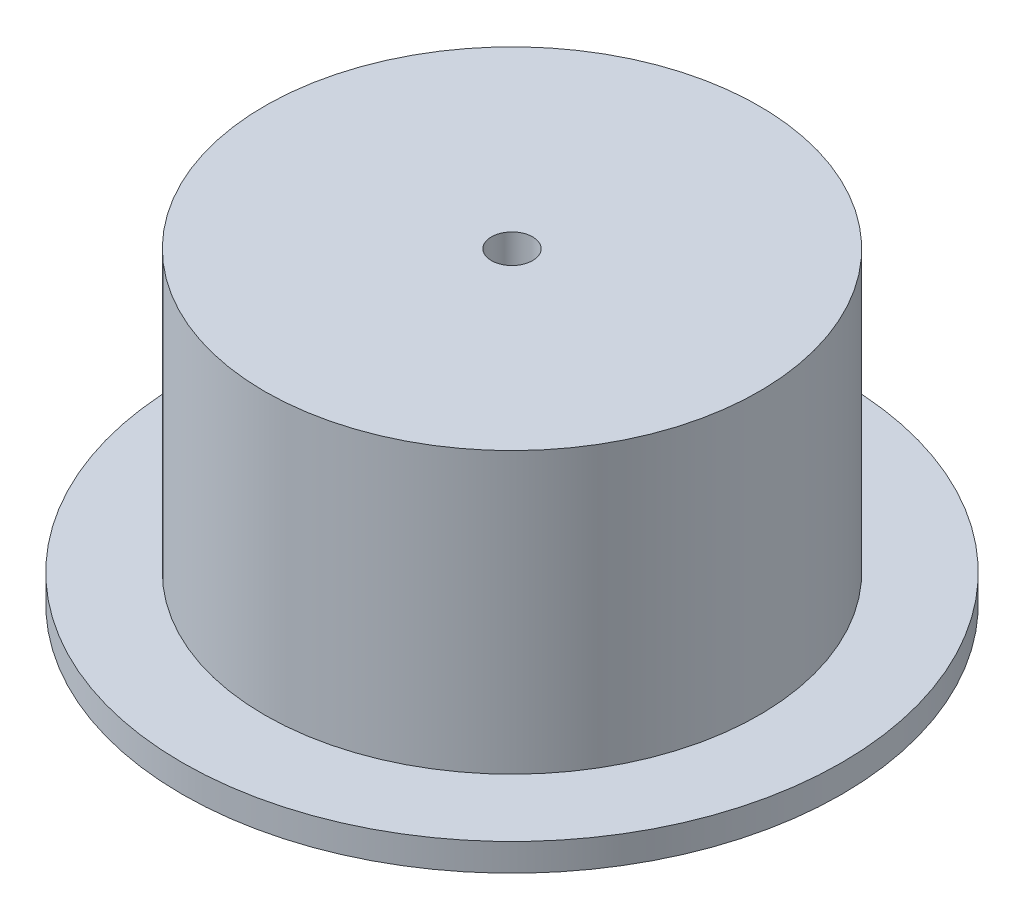
from build123d import *

# Parameters (mm, degrees)
SKETCH1_R           = 60
SKETCH1_R_2         = 45
BOSS_EXTRUDE1_DEPTH = 5
SKETCH2_R           = 45
SKETCH2_R_2         = 40
BOSS_EXTRUDE2_DEPTH = 56
SKETCH3_R           = 40
SKETCH3_R_2         = 3.75
BOSS_EXTRUDE3_DEPTH = 10


with BuildPart() as part:
    # Sketch1 → Boss-Extrude1 (new body)
    with BuildSketch(Plane(origin=(0, 0, 0), x_dir=(1, 0, 0), z_dir=(0, 1, 0))):
        Circle(SKETCH1_R)
        Circle(SKETCH1_R_2, mode=Mode.SUBTRACT)
    extrude(amount=BOSS_EXTRUDE1_DEPTH)

    # Sketch2 → Boss-Extrude2 (add)
    with BuildSketch(Plane(origin=(0, 0, 0), x_dir=(1, 0, 0), z_dir=(0, 1, 0))):
        Circle(SKETCH2_R)
        Circle(SKETCH2_R_2, mode=Mode.SUBTRACT)
    extrude(amount=BOSS_EXTRUDE2_DEPTH)

    # Sketch3 → Boss-Extrude3 (add)
    with BuildSketch(Plane(origin=(0, 56, 0), x_dir=(1, 0, 0), z_dir=(0, 1, 0))):
        Circle(SKETCH3_R)
        Circle(SKETCH3_R_2, mode=Mode.SUBTRACT)
    extrude(amount=-BOSS_EXTRUDE3_DEPTH)


solid = part.part
